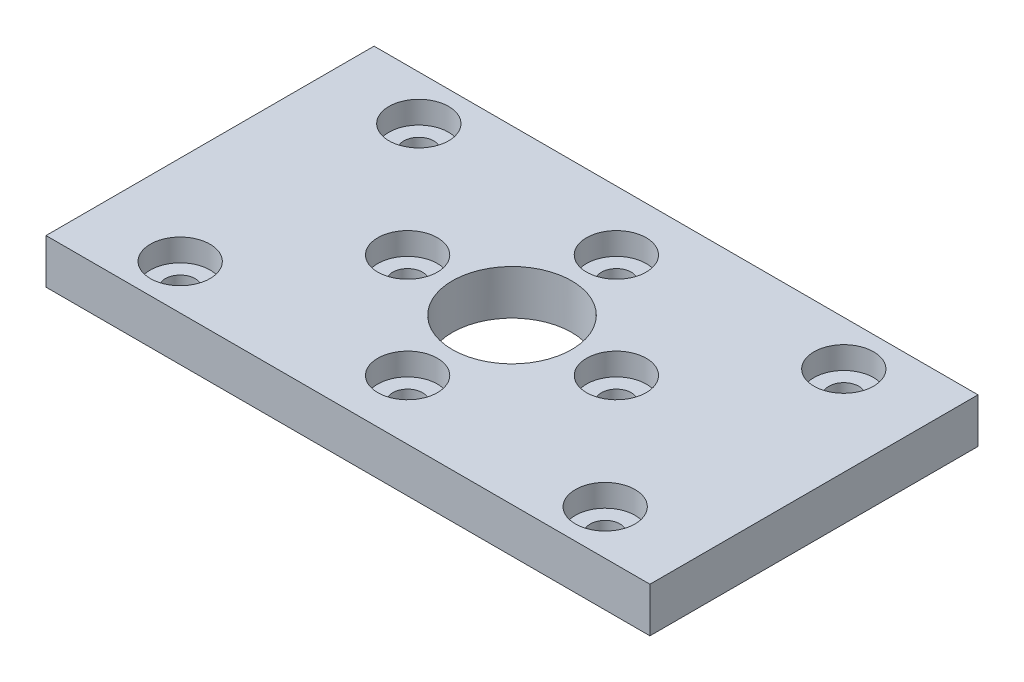
from build123d import *

# Parameters (mm, degrees)
SKETCH1_W           = 40.5
SKETCH1_H           = 22
BOSS_EXTRUDE1_DEPTH = 3
SKETCH2_R           = 1
CUT_EXTRUDE1_DEPTH  = 10
SKETCH3_R           = 4
CUT_EXTRUDE2_DEPTH  = 10
SKETCH4_R           = 1
CUT_EXTRUDE3_DEPTH  = 10
SKETCH5_R           = 2
CUT_EXTRUDE4_DEPTH  = 1.5


with BuildPart() as part:
    # Sketch1 → Boss-Extrude1 (new body)
    with BuildSketch(Plane(origin=(0, 0, 0), x_dir=(1, 0, 0), z_dir=(0, 1, 0))):
        Rectangle(SKETCH1_W, SKETCH1_H)
    extrude(amount=BOSS_EXTRUDE1_DEPTH)

    # Sketch2 → Cut-Extrude1 (cut)
    with BuildSketch(Plane(origin=(0, 3, 0), x_dir=(1, 0, 0), z_dir=(0, 1, 0))):
        with Locations((-14.25, 8)):
            Circle(SKETCH2_R)
        with Locations((-14.25, -8)):
            Circle(SKETCH2_R)
        with Locations((14.25, -8)):
            Circle(SKETCH2_R)
        with Locations((14.25, 8)):
            Circle(SKETCH2_R)
    extrude(amount=-CUT_EXTRUDE1_DEPTH, mode=Mode.SUBTRACT)

    # Sketch3 → Cut-Extrude2 (cut)
    with BuildSketch(Plane(origin=(0, 3, 0), x_dir=(1, 0, 0), z_dir=(0, 1, 0))):
        Circle(SKETCH3_R)
    extrude(amount=-CUT_EXTRUDE2_DEPTH, mode=Mode.SUBTRACT)

    # Sketch4 → Cut-Extrude3 (cut)
    with BuildSketch(Plane(origin=(0, 3, 0), x_dir=(1, 0, 0), z_dir=(0, 1, 0))):
        with Locations((0, 7)):
            Circle(SKETCH4_R)
        with Locations((7, 0)):
            Circle(SKETCH4_R)
        with Locations((0, -7)):
            Circle(SKETCH4_R)
        with Locations((-7, 0)):
            Circle(SKETCH4_R)
    extrude(amount=-CUT_EXTRUDE3_DEPTH, mode=Mode.SUBTRACT)

    # Sketch5 → Cut-Extrude4 (cut)
    with BuildSketch(Plane(origin=(0, 3, 0), x_dir=(1, 0, 0), z_dir=(0, 1, 0))):
        with Locations((14.25, 8)):
            Circle(SKETCH5_R)
        with Locations((0, 7)):
            Circle(SKETCH5_R)
        with Locations((-14.25, 8)):
            Circle(SKETCH5_R)
        with Locations((7, 0)):
            Circle(SKETCH5_R)
        with Locations((-7, 0)):
            Circle(SKETCH5_R)
        with Locations((-14.25, -8)):
            Circle(SKETCH5_R)
        with Locations((0, -7)):
            Circle(SKETCH5_R)
        with Locations((14.25, -8)):
            Circle(SKETCH5_R)
    extrude(amount=-CUT_EXTRUDE4_DEPTH, mode=Mode.SUBTRACT)


solid = part.part
